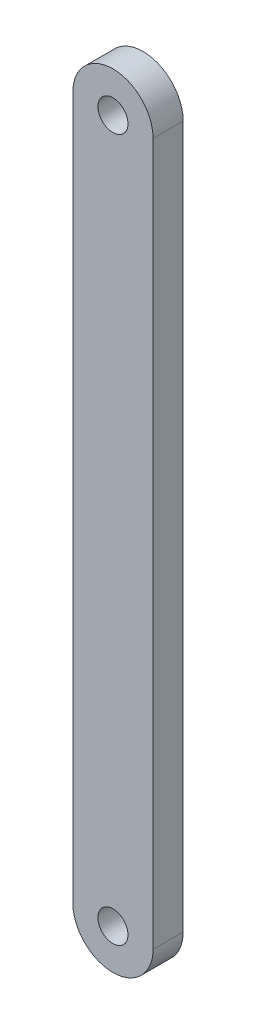
from build123d import *

# Parameters (mm, degrees)
SKETCH_1_W          = 8
SKETCH_1_H          = 70
EXTRUDE_1_DEPTH     = 3
SKETCH_2_R          = 4
EXTRUDE_2_DEPTH     = 3
SKETCH_3_R          = 1.5
CUT_EXTRUDE_1_DEPTH = 3


with BuildPart() as part:
    # 草图1 → 凸台-拉伸1 (new body)
    with BuildSketch(Plane.XY):
        Rectangle(SKETCH_1_W, SKETCH_1_H)
    extrude(amount=EXTRUDE_1_DEPTH)

    # 草图2 → 凸台-拉伸2 (add)
    with BuildSketch(Plane.XY):
        with Locations((0, 35)):
            Circle(SKETCH_2_R)
        with Locations((0, -35)):
            Circle(SKETCH_2_R)
    extrude(amount=EXTRUDE_2_DEPTH)

    # 草图3 → 切除-拉伸1 (cut)
    with BuildSketch(Plane.XY.offset(3)):
        with Locations((0, 35)):
            Circle(SKETCH_3_R)
        with Locations((0, -35)):
            Circle(SKETCH_3_R)
    extrude(amount=-CUT_EXTRUDE_1_DEPTH, mode=Mode.SUBTRACT)


solid = part.part
